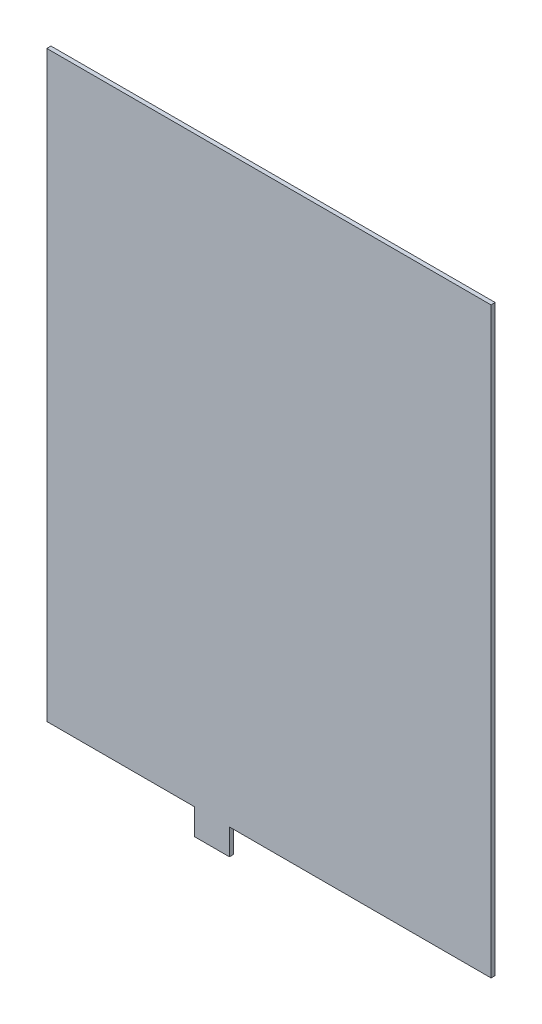
from build123d import *

# Parameters (mm, degrees)
SKETCH_1_W      = 171.5
SKETCH_1_H      = 225
SKETCH_1_W_2    = 13.5
SKETCH_1_H_2    = 10
EXTRUDE_1_DEPTH = 1.6


with BuildPart() as part:
    # Эскиз1 → Бобышка-Вытянуть1 (new body)
    with BuildSketch(Plane.XY):
        Rectangle(SKETCH_1_W, SKETCH_1_H)
        with Locations((-22, -117.5)):
            Rectangle(SKETCH_1_W_2, SKETCH_1_H_2)
    extrude(amount=EXTRUDE_1_DEPTH)


solid = part.part
